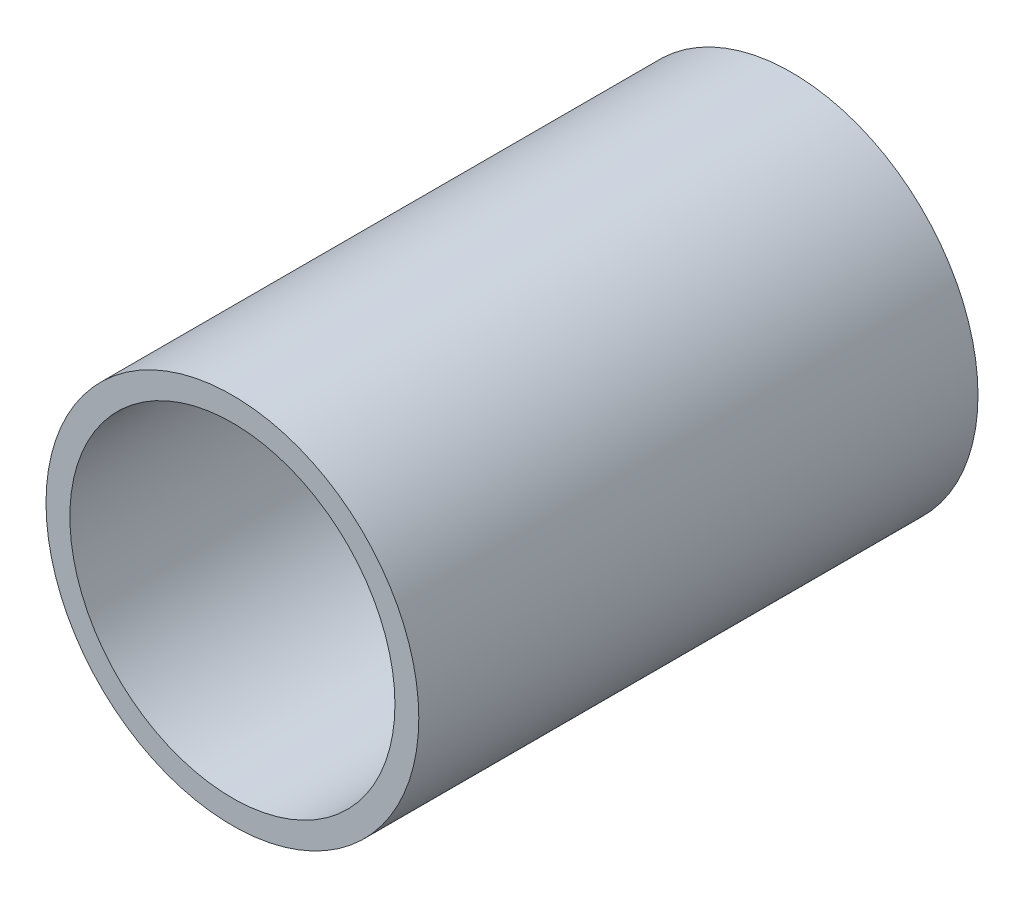
from build123d import *

# Parameters (mm, degrees)
SKETCH2_R           = 6.35
SKETCH2_R_2         = 5.5372
BOSS_EXTRUDE1_DEPTH = 9.525


with BuildPart() as part:
    # Sketch2 → Boss-Extrude1 (new, symmetric)
    with BuildSketch(Plane.XY):
        Circle(SKETCH2_R)
        Circle(SKETCH2_R_2, mode=Mode.SUBTRACT)
    extrude(amount=BOSS_EXTRUDE1_DEPTH, both=True)


solid = part.part
